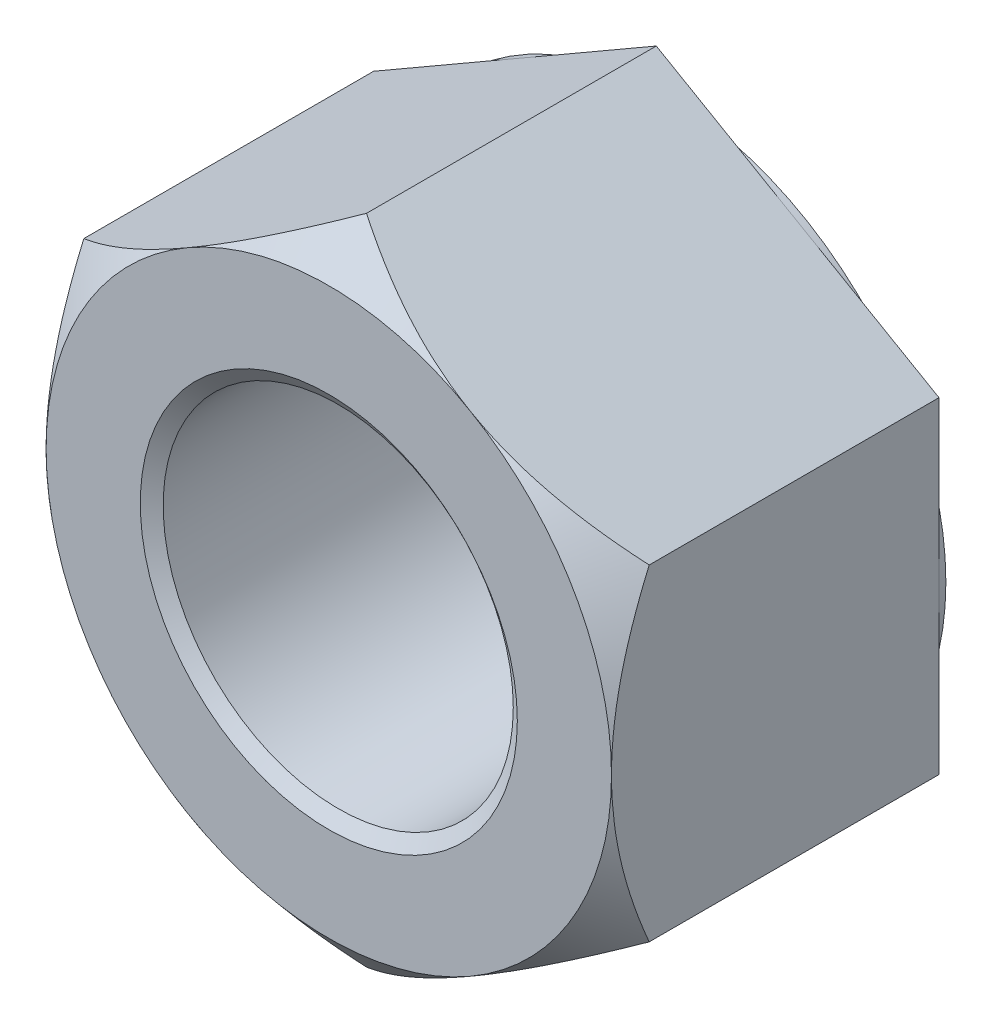
from build123d import *

# Parameters (mm, degrees)
BASENUTSKE_R  = 10.31875
BASENUT_DEPTH = 19.7104
SKETCH4_W     = 0.4064
SKETCH4_H     = 15.277682251


with BuildPart() as part:
    # BaseNutSke → BaseNut (new body)
    with BuildSketch(Plane.XY):
        Polygon((16.6624, 9.620041125), (16.6624, -9.620041125), (0, -19.240082251), (-16.6624, -9.620041125), (-16.6624, 9.620041125), (0, 19.240082251), align=None)
        Circle(BASENUTSKE_R, mode=Mode.SUBTRACT)
    extrude(amount=-BASENUT_DEPTH)

    # Sketch4 → Bearing-Face (revolve, cut)
    with BuildSketch(Plane(origin=(0, 0, 0), x_dir=(0, 0, -1), z_dir=(1, 0, 0))):
        with Locations((19.5072, 24.301241126)):
            Rectangle(SKETCH4_W, SKETCH4_H)
        Polygon((0, 16.6624), (-12.7, 16.6624), (-12.7, 31.940082251), (2.2225, 31.940082251), (2.2225, 19.240082251), align=None)
    revolve(axis=Axis((0, 0, 0), (0, 0, -1)), mode=Mode.SUBTRACT)

    # Sketch5 → EndChamfer (revolve, cut)
    with BuildSketch(Plane(origin=(0, 0, 0), x_dir=(0, 0, -1), z_dir=(1, 0, 0))):
        Polygon((19.685, 11.1125), (19.073631293, 10.239375), (19.7358, 10.239375), (19.7358, 11.1125), align=None)
        Polygon((-0.0508, 11.1125), (0, 11.1125), (0.611368707, 10.239375), (-0.0508, 10.239375), align=None)
    revolve(axis=Axis((0, 0, -25.037505729), (0, 0, -1)), mode=Mode.SUBTRACT)


solid = part.part
